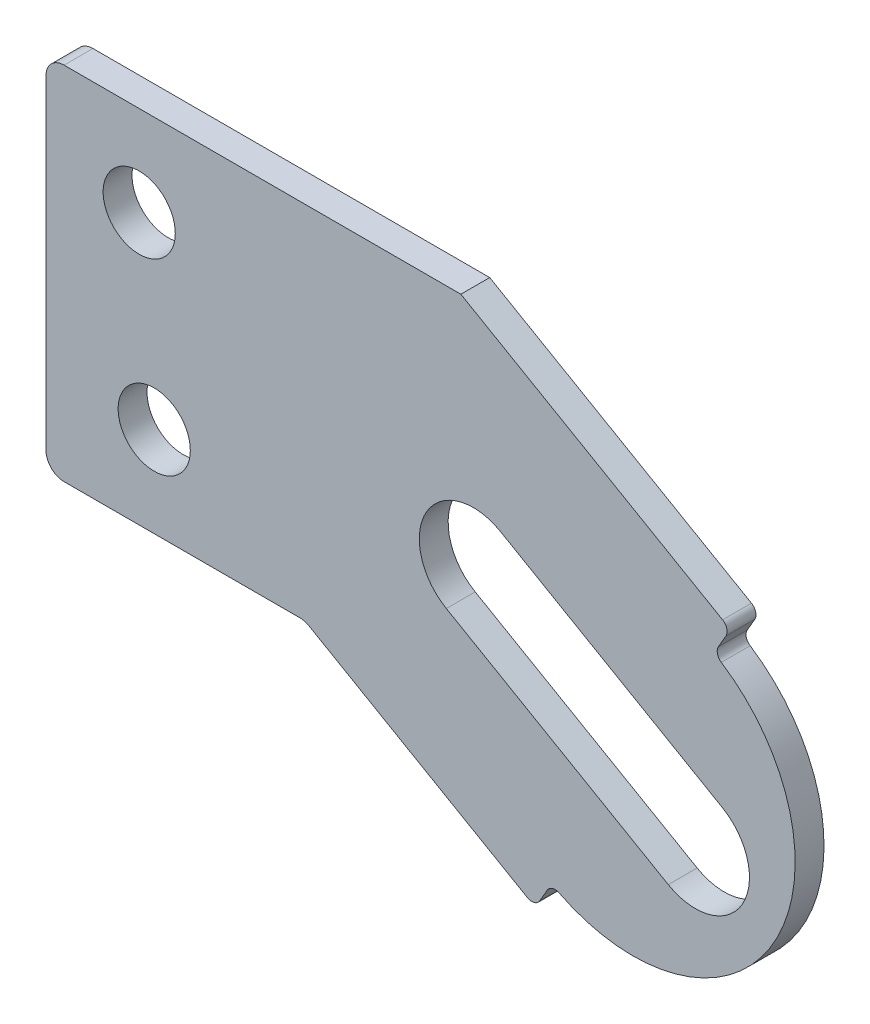
from build123d import *

# Parameters (mm, degrees)
SKETCH1_R           = 0.25
BOSS_EXTRUDE5_DEPTH = 0.2


with BuildPart() as part:
    # Sketch1 → Boss-Extrude5 (new body)
    with BuildSketch(Plane.XY):
        with BuildLine():
            Line((-4.5, 2.375), (-4.5, 0.125))
            ThreePointArc((-4.5, 0.125), (-4.463388348, 0.036611652), (-4.375, 0))
            Line((-4.375, 0), (-2.74036663, 0))
            ThreePointArc((-2.74036663, 0), (-2.708014249, -0.004259272), (-2.67786663, -0.016746825))
            Line((-2.67786663, -0.016746825), (-1.164290548, -0.890610383))
            ThreePointArc((-1.164290548, -0.890610383), (-1.116484948, -0.89690411), (-1.078230947, -0.867550783))
            Line((-1.078230947, -0.867550783), (-1.026395132, -0.777768517))
            ThreePointArc((-1.026395132, -0.777768517), (-0.989749497, -0.748869098), (-0.943273167, -0.753115233))
            ThreePointArc((-0.943273167, -0.753115233), (0.541047632, -0.312878012), (0.180143849, 1.192700118))
            ThreePointArc((0.180143849, 1.192700118), (0.153228424, 1.230826733), (0.159933238, 1.277012493))
            Line((0.159933238, 1.277012493), (0.211769053, 1.366794759))
            ThreePointArc((0.211769053, 1.366794759), (0.218062779, 1.414600359), (0.188709452, 1.452854359))
            Line((0.188709452, 1.452854359), (-1.625, 2.5))
            Line((-1.625, 2.5), (-4.375, 2.5))
            ThreePointArc((-4.375, 2.5), (-4.463388348, 2.463388348), (-4.5, 2.375))
        make_face()
        with Locations((-3.854119775, 1.875)):
            Circle(SKETCH1_R, mode=Mode.SUBTRACT)
        with Locations((-3.75, 0.625)):
            Circle(SKETCH1_R, mode=Mode.SUBTRACT)
        with BuildLine():
            Line((-0.1875, -0.324759526), (-1.725595036, 0.563260057))
            ThreePointArc((-1.725595036, 0.563260057), (-1.862854562, 1.075519583), (-1.350595036, 1.212779109))
            Line((-1.350595036, 1.212779109), (0.1875, 0.324759526))
            ThreePointArc((0.1875, 0.324759526), (0.324759526, -0.1875), (-0.1875, -0.324759526))
        make_face(mode=Mode.SUBTRACT)
    extrude(amount=BOSS_EXTRUDE5_DEPTH)


solid = part.part
